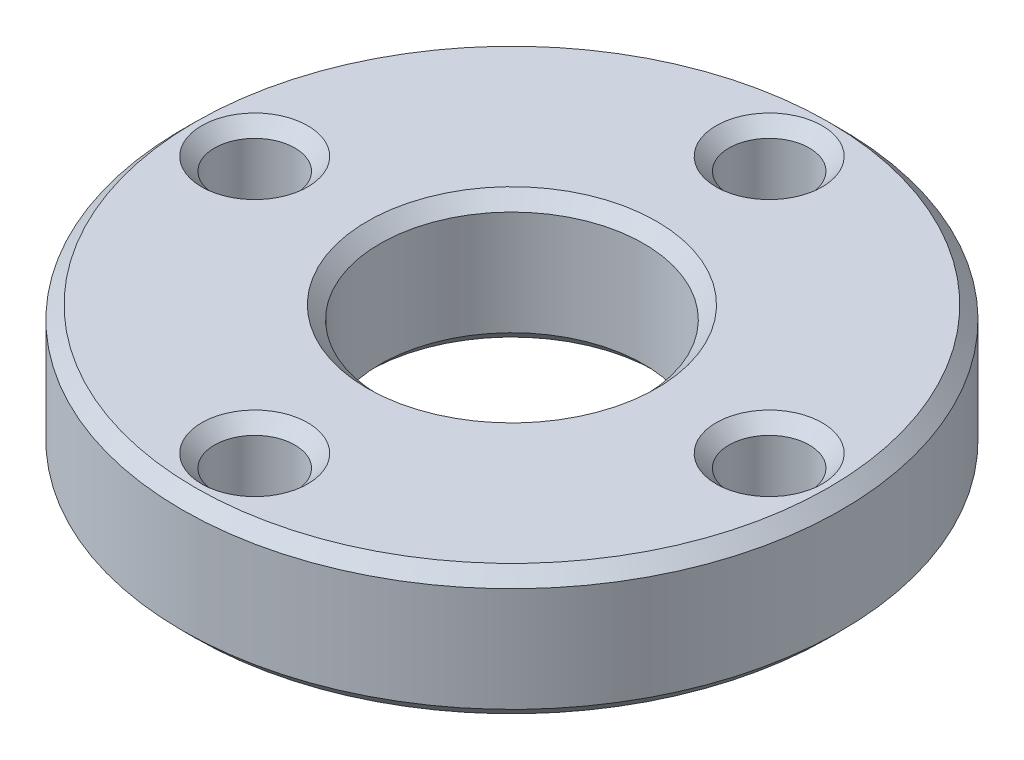
from build123d import *

# Parameters (mm, degrees)
SKETCH1_R           = 10.25
SKETCH1_R_2         = 4.1
BOSS_EXTRUDE1_DEPTH = 4.05
SKETCH4_R           = 1.25
CUT_EXTRUDE1_DEPTH  = 5.05
CIRPATTERN1_COUNT   = 4
CHAMFER1_SIZE       = 0.4


with BuildPart() as part:
    # Sketch1 → Boss-Extrude1 (new body)
    with BuildSketch(Plane(origin=(0, 0, 0), x_dir=(1, 0, 0), z_dir=(0, 1, 0))):
        Circle(SKETCH1_R)
        Circle(SKETCH1_R_2, mode=Mode.SUBTRACT)
    extrude(amount=-BOSS_EXTRUDE1_DEPTH)

    # Sketch4 → Cut-Extrude1 (cut, through all)
    with BuildSketch(Plane(origin=(0, 0, 0), x_dir=(1, 0, 0), z_dir=(0, 1, 0))):
        with Locations((0, 8)):
            Circle(SKETCH4_R)
    cut_extrude1 = extrude(amount=-CUT_EXTRUDE1_DEPTH, mode=Mode.SUBTRACT)

    # CirPattern1: Cut-Extrude1 ×4 about axis
    cirpattern1_axis = Axis((0, 0, 0), (0, 1, 0))
    for i in range(1, CIRPATTERN1_COUNT):
        add(cut_extrude1.rotate(cirpattern1_axis, i * 360 / CIRPATTERN1_COUNT), mode=Mode.SUBTRACT)

    # Chamfer1
    chamfer1_edges = [part.edges().sort_by_distance(p)[0] for p in [
        (-1.25, -4.05, -8),
        (-1.25, 0, -8),
        (-10.25, 0, 0),
        (-8, -4.05, 1.25),
        (-8, 0, 1.25),
        (1.25, -4.05, 8),
        (1.25, 0, 8),
        (8, -4.05, -1.25),
        (8, 0, -1.25),
        (-10.25, -4.05, 0),
        (-4.1, -4.05, 0),
        (-4.1, 0, 0),
    ]]
    chamfer(chamfer1_edges, length=CHAMFER1_SIZE)


solid = part.part
